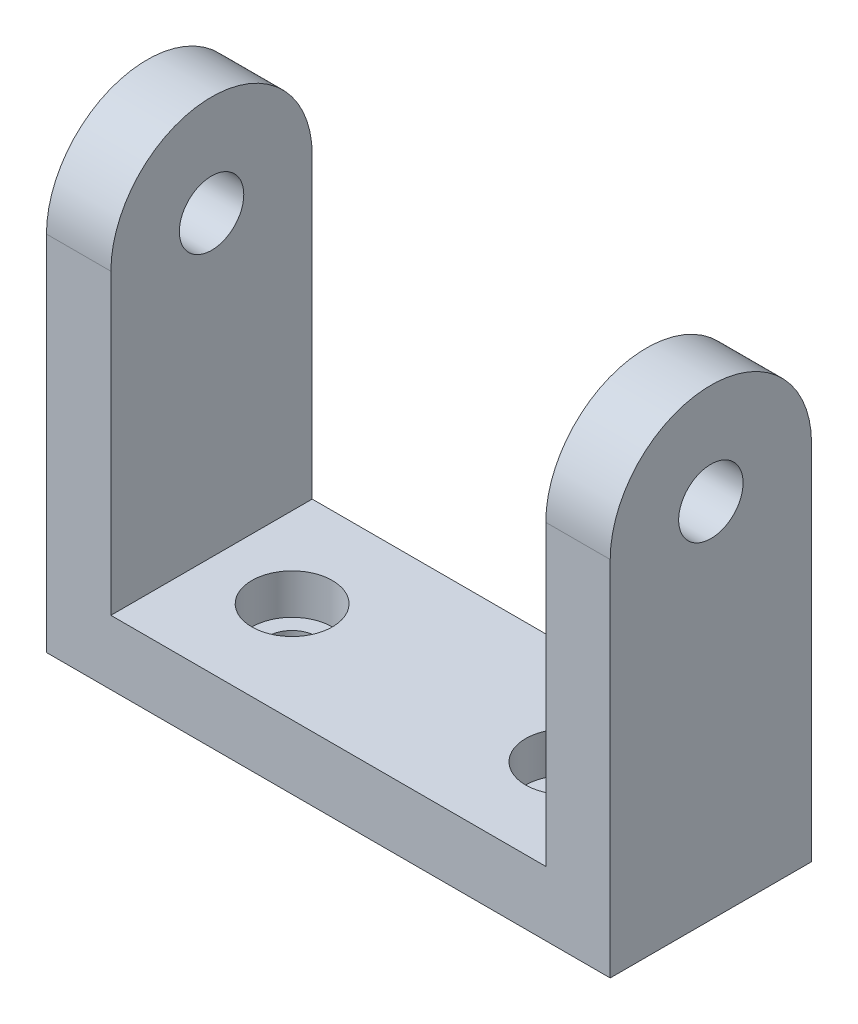
from build123d import *

# Parameters (mm, degrees)
SKETCH1_W           = 70
SKETCH1_H           = 25
BOSS_EXTRUDE1_DEPTH = 8
SKETCH2_R           = 3
CUT_EXTRUDE1_DEPTH  = 47.071307397
SKETCH2_3_R         = 5
CUT_EXTRUDE2_DEPTH  = 5
SKETCH3_R           = 4
BOSS_EXTRUDE2_DEPTH = 8


with BuildPart() as part:
    # Sketch1 → Boss-Extrude1 (new body)
    with BuildSketch(Plane(origin=(0, 0, 0), x_dir=(1, 0, 0), z_dir=(0, 1, 0))):
        with Locations((8.045977011, 1.83908046)):
            Rectangle(SKETCH1_W, SKETCH1_H)
    extrude(amount=BOSS_EXTRUDE1_DEPTH)

    # Sketch2 → Cut-Extrude1 (cut, through all)
    with BuildSketch(Plane(origin=(0, 8, 0), x_dir=(1, 0, 0), z_dir=(0, 1, 0))):
        with Locations((25.045977011, 1.83908046)):
            Circle(SKETCH2_R)
    cut_extrude1 = extrude(amount=-CUT_EXTRUDE1_DEPTH, mode=Mode.SUBTRACT)

    # Sketch2_3 → Cut-Extrude2 (cut)
    with BuildSketch(Plane(origin=(0, 8, 0), x_dir=(1, 0, 0), z_dir=(0, 1, 0))):
        with Locations((25.045977011, 1.83908046)):
            Circle(SKETCH2_3_R)
    cut_extrude2 = extrude(amount=-CUT_EXTRUDE2_DEPTH, mode=Mode.SUBTRACT)

    # Sketch3 → Boss-Extrude2 (add)
    with BuildSketch(Plane(origin=(43.045977011, 0, 0), x_dir=(0, 0, -1), z_dir=(1, 0, 0))):
        with BuildLine():
            Line((-10.66091954, 45), (-10.66091954, 8))
            Line((-10.66091954, 8), (14.33908046, 8))
            Line((14.33908046, 8), (14.33908046, 45))
            ThreePointArc((14.33908046, 45), (1.83908046, 57.5), (-10.66091954, 45))
        make_face()
        with Locations((1.83908046, 45)):
            Circle(SKETCH3_R, mode=Mode.SUBTRACT)
    boss_extrude2 = extrude(amount=-BOSS_EXTRUDE2_DEPTH)

    # Mirror1: Cut-Extrude1, Cut-Extrude2, Boss-Extrude2 across plane
    add(cut_extrude1.mirror(Plane(origin=(8.045977011, 0, 0), x_dir=(0, 0, 1), z_dir=(1, 0, 0))), mode=Mode.SUBTRACT)
    add(cut_extrude2.mirror(Plane(origin=(8.045977011, 0, 0), x_dir=(0, 0, 1), z_dir=(1, 0, 0))), mode=Mode.SUBTRACT)
    add(boss_extrude2.mirror(Plane(origin=(8.045977011, 0, 0), x_dir=(0, 0, 1), z_dir=(1, 0, 0))))


solid = part.part
